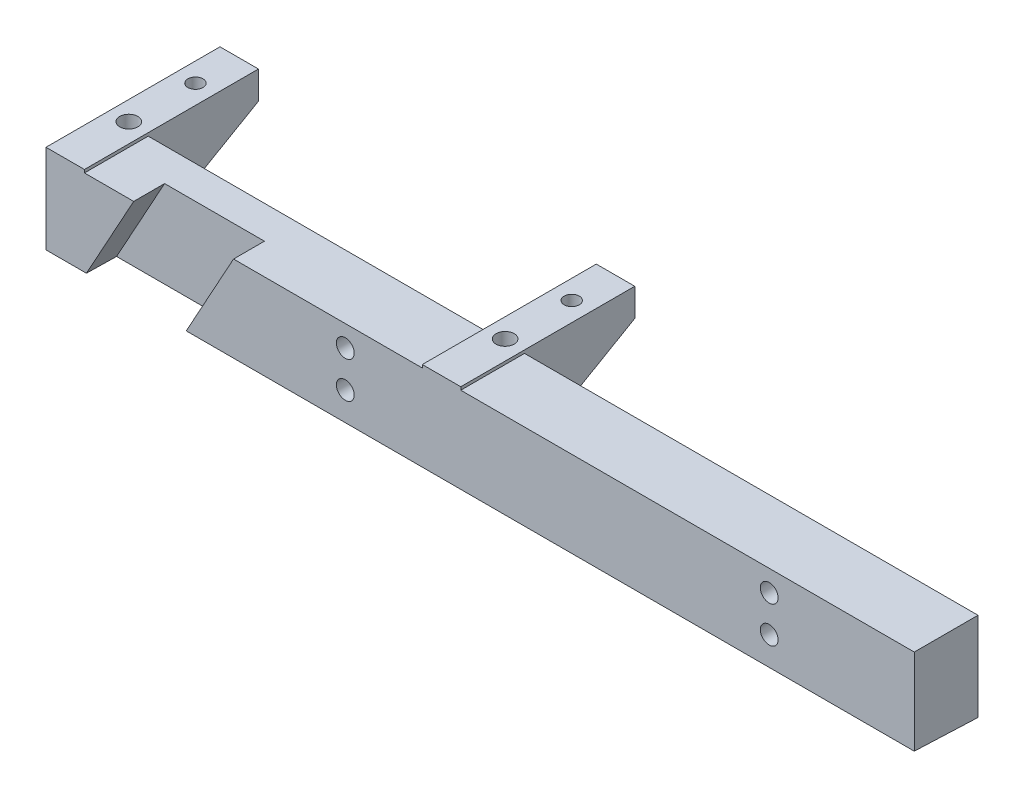
from build123d import *

# Parameters (mm, degrees)
EXTRUDE2_DEPTH                 = 143.3725
BOSS_EXTRUDE4_DEPTH            = 6.35
BOSS_EXTRUDE5_DEPTH            = 6.35
M3X0_5_TAPPED_HOLE1_D          = 3
M3X0_5_TAPPED_HOLE1_DEPTH      = 7.5
M3X0_5_TAPPED_HOLE1_TIP        = 0.901290929
F_2_5_2_5_DIAMETER_HOLE1_D     = 2.5
F_2_5_2_5_DIAMETER_HOLE1_DEPTH = 6.35
F_2_5_2_5_DIAMETER_HOLE1_TIP   = 0.751075774
CUT_EXTRUDE1_DEPTH             = 5.1
F_4_CLEARANCE_HOLE1_D          = 2.9464


with BuildPart() as part:
    # Sketch73 → Extrude2 (new body)
    with BuildSketch(Plane(origin=(0, 0, 0), x_dir=(0, 0, -1), z_dir=(1, 0, 0))):
        Polygon((0, 0), (10.525, 0), (10.525, -14.62), (0, -14.18), align=None)
    extrude(amount=EXTRUDE2_DEPTH)

    # Sketch113 → Boss-Extrude4 (add)
    with BuildSketch(Plane.ZY):
        Polygon((-28.732, 0.5), (0, 0.5), (0, -14.18), (-10.525, -14.62), (-28.732, -4.108183649), align=None)
    extrude(amount=-BOSS_EXTRUDE4_DEPTH)

    # Sketch114 → Boss-Extrude5 (add)
    with BuildSketch(Plane.ZY.offset(-62.1372)):
        Polygon((-10.525, -14.62), (-10.525, 0), (0, 0), (0, 0.5), (-28.732, 0.5), (-28.732, -4.108183649), align=None)
    extrude(amount=-BOSS_EXTRUDE5_DEPTH)

    # M3x0.5 Tapped Hole1
    with Locations(Plane(origin=(-41.488675912, 0.5, -11.380370452), x_dir=(-1, 0, 0), z_dir=(0, 1, 0))):
        with Locations((-106.800875912, 0.880370452), (-44.663675912, 0.880370452)):
            Hole(M3X0_5_TAPPED_HOLE1_D / 2, depth=M3X0_5_TAPPED_HOLE1_DEPTH)
            with Locations((0, 0, -(M3X0_5_TAPPED_HOLE1_DEPTH + M3X0_5_TAPPED_HOLE1_TIP / 2))):  # 118° drill point
                Cone(0, M3X0_5_TAPPED_HOLE1_D / 2, M3X0_5_TAPPED_HOLE1_TIP, mode=Mode.SUBTRACT)

    # 2.5 _2.5_ Diameter Hole1
    with Locations(Plane(origin=(0, 0.5, 0), x_dir=(-1, 0, 0), z_dir=(0, 1, 0))):
        with Locations((-3.175, -21.5), (-65.3122, -21.5)):
            Hole(F_2_5_2_5_DIAMETER_HOLE1_D / 2, depth=F_2_5_2_5_DIAMETER_HOLE1_DEPTH)
            with Locations((0, 0, -(F_2_5_2_5_DIAMETER_HOLE1_DEPTH + F_2_5_2_5_DIAMETER_HOLE1_TIP / 2))):  # 118° drill point
                Cone(0, F_2_5_2_5_DIAMETER_HOLE1_D / 2, F_2_5_2_5_DIAMETER_HOLE1_TIP, mode=Mode.SUBTRACT)

    # Sketch117 → Cut-Extrude1 (cut)
    with BuildSketch(Plane.XY):
        Polygon((30.967580189, 0), (14.483, 0), (6.432290426, -14.62), (22.916870615, -14.62), align=None)
    extrude(amount=-CUT_EXTRUDE1_DEPTH, mode=Mode.SUBTRACT)

    # 4 Clearance Hole1 (through all)
    with Locations(Plane(origin=(0, 0, -10.525), x_dir=(-1, 0, 0), z_dir=(0, 0, -1))):
        with Locations((-119.4195, -3.5), (-119.4195, -9.5), (-49.4195, -3.5), (-49.4195, -9.5)):
            Hole(F_4_CLEARANCE_HOLE1_D / 2)


solid = part.part
